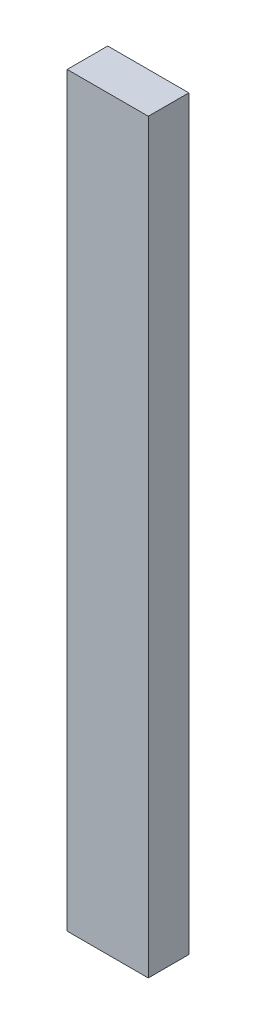
from build123d import *

# Parameters (mm, degrees)
SKETCH1_W           = 0.5
SKETCH1_H           = 0.25
BOSS_EXTRUDE1_DEPTH = 4.6


with BuildPart() as part:
    # Sketch1 → Boss-Extrude1 (new body)
    with BuildSketch(Plane(origin=(0, 0, 0), x_dir=(1, 0, 0), z_dir=(0, 1, 0))):
        Rectangle(SKETCH1_W, SKETCH1_H)
    extrude(amount=BOSS_EXTRUDE1_DEPTH)


solid = part.part
